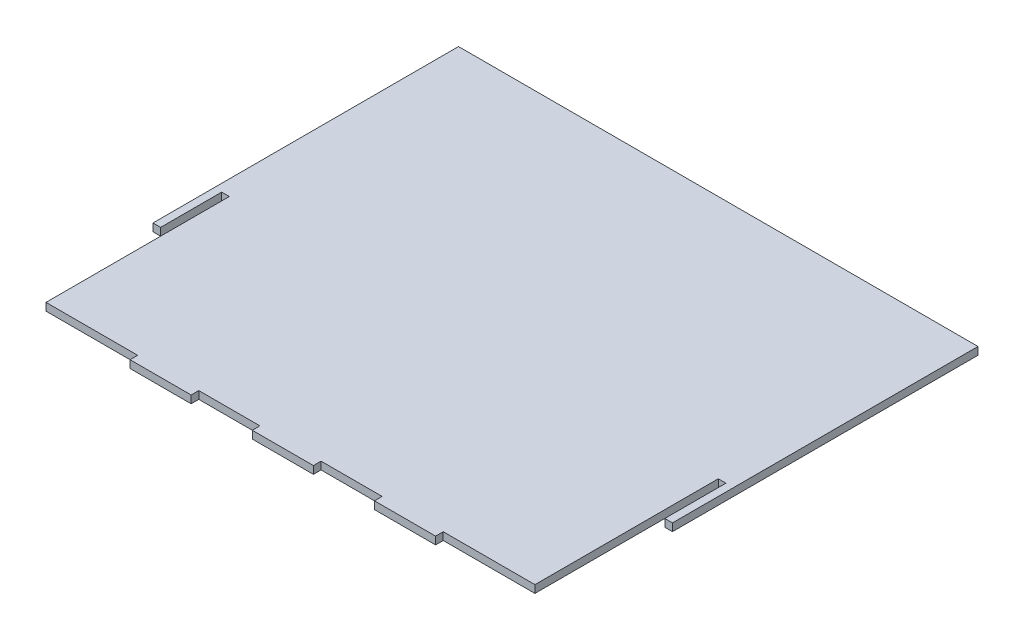
from build123d import *

# Parameters (mm, degrees)
SKETCH1_W           = 25.4
SKETCH1_H           = 3.175
BOSS_EXTRUDE1_DEPTH = 1.5875


with BuildPart() as part:
    # Sketch1 → Boss-Extrude1 (new body, symmetric)
    with BuildSketch(Plane(origin=(0, 0, 0), x_dir=(1, 0, 0), z_dir=(0, 1, 0))):
        Polygon((-101.6, -12.7), (-101.6, -88.9), (-63.5, -88.9), (-38.1, -88.9), (-12.7, -88.9), (12.7, -88.9), (38.1, -88.9), (63.5, -88.9), (101.6, -88.9), (101.6, -12.7), (104.775, -12.7), (104.775, -38.1), (107.95, -38.1), (107.95, 88.9), (-107.95, 88.9), (-107.95, -38.1), (-104.775, -38.1), (-104.775, -12.7), align=None)
        with Locations((-50.8, -90.4875)):
            Rectangle(SKETCH1_W, SKETCH1_H)
        with Locations((0, -90.4875)):
            Rectangle(SKETCH1_W, SKETCH1_H)
        with Locations((50.8, -90.4875)):
            Rectangle(SKETCH1_W, SKETCH1_H)
    extrude(amount=BOSS_EXTRUDE1_DEPTH, both=True)


solid = part.part
